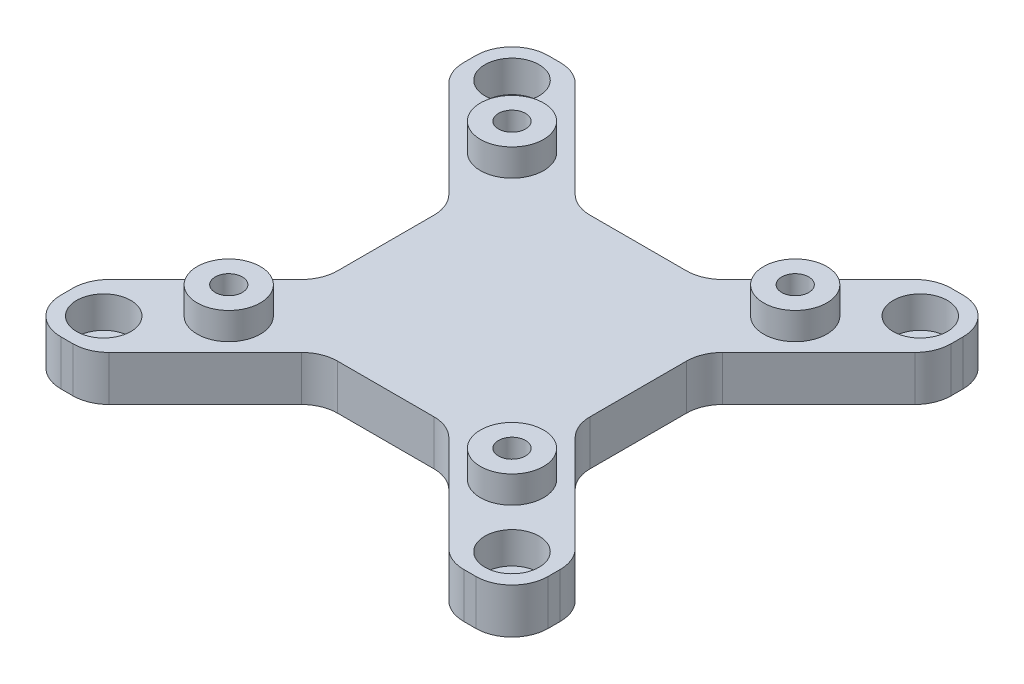
from build123d import *

# Parameters (mm, degrees)
SZKIC2_R                    = 1.7
SZKIC2_R_2                  = 1.5
DODANIE_WYCI_GNI_CIE1_DEPTH = 5
DODANIE_WYCI_GNI_CIE2_START = 3
SZKIC2_3_R                  = 3.5
SZKIC2_3_R_2                = 1.5
DODANIE_WYCI_GNI_CIE2_DEPTH = 3
WYTNIJ_WYCI_GNI_CIE1_DEPTH  = 39.509739028
SZYK_KO_OWY1_COUNT          = 4
ZAOKR_GLENIE1_R             = 4
SZKIC5_R                    = 3
WYTNIJ_WYCI_GNI_CIE3_DEPTH  = 3.5


with BuildPart() as part:
    # Szkic2 → Dodanie-wyci_gni_cie1 (new body)
    with BuildSketch(Plane(origin=(0, 0, 0), x_dir=(1, 0, 0), z_dir=(0, 1, 0))):
        with BuildLine():
            ThreePointArc((-27, -23), (-25.828427125, -25.828427125), (-23, -27))
            Line((-23, -27), (23, -27))
            ThreePointArc((23, -27), (25.828427125, -25.828427125), (27, -23))
            Line((27, -23), (27, 23))
            ThreePointArc((27, 23), (25.828427125, 25.828427125), (23, 27))
            Line((23, 27), (-23, 27))
            ThreePointArc((-23, 27), (-25.828427125, 25.828427125), (-27, 23))
            Line((-27, 23), (-27, -23))
        make_face()
        with Locations((-22.625, -22.625)):
            Circle(SZKIC2_R, mode=Mode.SUBTRACT)
        with Locations((22.625, -22.625)):
            Circle(SZKIC2_R, mode=Mode.SUBTRACT)
        with Locations((-22.625, 22.625)):
            Circle(SZKIC2_R, mode=Mode.SUBTRACT)
        with Locations((22.625, 22.625)):
            Circle(SZKIC2_R, mode=Mode.SUBTRACT)
        with Locations((-15.695, -15.695)):
            Circle(SZKIC2_R_2, mode=Mode.SUBTRACT)
        with Locations((15.695, -15.695)):
            Circle(SZKIC2_R_2, mode=Mode.SUBTRACT)
        with Locations((-15.695, 15.695)):
            Circle(SZKIC2_R_2, mode=Mode.SUBTRACT)
        with Locations((15.695, 15.695)):
            Circle(SZKIC2_R_2, mode=Mode.SUBTRACT)
    extrude(amount=-DODANIE_WYCI_GNI_CIE1_DEPTH)

    # Szkic2_3 → Dodanie-wyci_gni_cie2 (add)
    # profile 1 of 4: a face of its own
    with BuildSketch(Plane(origin=(0, 0, 0), x_dir=(1, 0, 0), z_dir=(0, 1, 0)).offset(DODANIE_WYCI_GNI_CIE2_START)):
        with Locations((-15.695, 15.695)):
            Circle(SZKIC2_3_R)
        with Locations((-15.695, 15.695)):
            Circle(SZKIC2_3_R_2, mode=Mode.SUBTRACT)
    # profile 2 of 4: a face of its own
    with BuildSketch(Plane(origin=(0, 0, 0), x_dir=(1, 0, 0), z_dir=(0, 1, 0)).offset(DODANIE_WYCI_GNI_CIE2_START)):
        with Locations((15.695, 15.695)):
            Circle(SZKIC2_3_R)
        with Locations((15.695, 15.695)):
            Circle(SZKIC2_3_R_2, mode=Mode.SUBTRACT)
    # profile 3 of 4: a face of its own
    with BuildSketch(Plane(origin=(0, 0, 0), x_dir=(1, 0, 0), z_dir=(0, 1, 0)).offset(DODANIE_WYCI_GNI_CIE2_START)):
        with Locations((-15.695, -15.695)):
            Circle(SZKIC2_3_R)
        with Locations((-15.695, -15.695)):
            Circle(SZKIC2_3_R_2, mode=Mode.SUBTRACT)
    # profile 4 of 4: a face of its own
    with BuildSketch(Plane(origin=(0, 0, 0), x_dir=(1, 0, 0), z_dir=(0, 1, 0)).offset(DODANIE_WYCI_GNI_CIE2_START)):
        with Locations((15.695, -15.695)):
            Circle(SZKIC2_3_R)
        with Locations((15.695, -15.695)):
            Circle(SZKIC2_3_R_2, mode=Mode.SUBTRACT)
    extrude(amount=-DODANIE_WYCI_GNI_CIE2_DEPTH)

    # Szkic3 → Wytnij-wyci_gni_cie1 (cut, through all)
    with BuildSketch(Plane(origin=(0, 0, 0), x_dir=(1, 0, 0), z_dir=(0, 1, 0))):
        Polygon((-7, -14), (7, -14), (20, -27), (-20, -27), align=None)
    wytnij_wyci_gni_cie1 = extrude(amount=-WYTNIJ_WYCI_GNI_CIE1_DEPTH, mode=Mode.SUBTRACT)

    # Szyk ko_owy1: Wytnij-wyci_gni_cie1 ×4 about axis
    szyk_ko_owy1_axis = Axis((0, -8.6, 0), (0, 1, 0))
    for i in range(1, SZYK_KO_OWY1_COUNT):
        add(wytnij_wyci_gni_cie1.rotate(szyk_ko_owy1_axis, i * 360 / SZYK_KO_OWY1_COUNT), mode=Mode.SUBTRACT)

    # Zaokr_glenie1
    zaokr_glenie1_edges = [part.edges().sort_by_distance(p)[0] for p in [
        (20, -2.5, 27),
        (7, -2.5, 14),
        (-20, -2.5, 27),
        (-7, -2.5, 14),
        (27, -2.5, -20),
        (14, -2.5, -7),
        (14, -2.5, 7),
        (27, -2.5, 20),
        (20, -2.5, -27),
        (7, -2.5, -14),
        (-20, -2.5, -27),
        (-7, -2.5, -14),
        (-27, -2.5, 20),
        (-14, -2.5, 7),
        (-14, -2.5, -7),
        (-27, -2.5, -20),
    ]]
    fillet(zaokr_glenie1_edges, radius=ZAOKR_GLENIE1_R)

    # Szkic5 → Wytnij-wyci_gni_cie3 (cut)
    with BuildSketch(Plane(origin=(0, 0, 0), x_dir=(1, 0, 0), z_dir=(0, 1, 0))):
        with Locations((-22.625, -22.625)):
            Circle(SZKIC5_R)
        with Locations((-22.625, 22.625)):
            Circle(SZKIC5_R)
        with Locations((22.625, 22.625)):
            Circle(SZKIC5_R)
        with Locations((22.625, -22.625)):
            Circle(SZKIC5_R)
    extrude(amount=-WYTNIJ_WYCI_GNI_CIE3_DEPTH, mode=Mode.SUBTRACT)


solid = part.part
